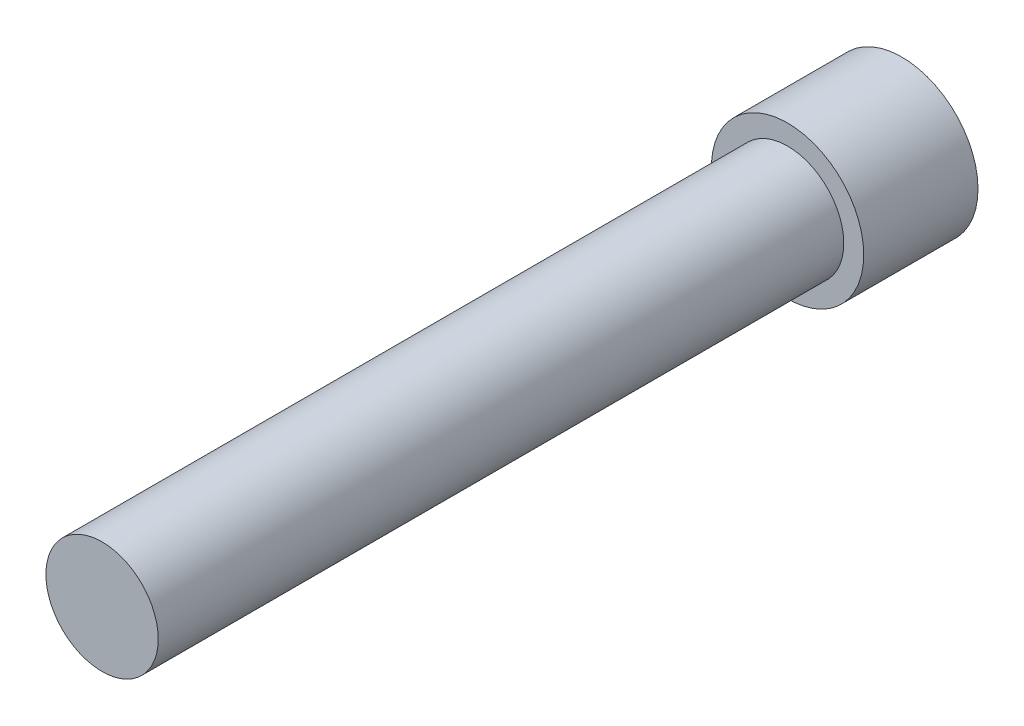
from build123d import *

# Parameters (mm, degrees)
SKETCH1_R      = 2
EXTRUDE1_DEPTH = 3
EXTRUDE3_DEPTH = 1.82
SKETCH2_R      = 1.475
EXTRUDE2_DEPTH = 18


with BuildPart() as part:
    # Sketch1 → Extrude1 (new body)
    with BuildSketch(Plane.XY):
        Circle(SKETCH1_R)
    extrude(amount=EXTRUDE1_DEPTH)

    # Sketch3 → Extrude3 (cut)
    with BuildSketch(Plane(origin=(0, 0, 0), x_dir=(-1, 0, 0), z_dir=(0, 0, -1))):
        Polygon((-1.443375673, 0), (-0.721687836, -1.25), (0.721687836, -1.25), (1.443375673, 0), (0.721687836, 1.25), (-0.721687836, 1.25), align=None)
    extrude(amount=-EXTRUDE3_DEPTH, mode=Mode.SUBTRACT)

    # Sketch2 → Extrude2 (add)
    with BuildSketch(Plane.XY.offset(3)):
        Circle(SKETCH2_R)
    extrude(amount=EXTRUDE2_DEPTH)


solid = part.part
